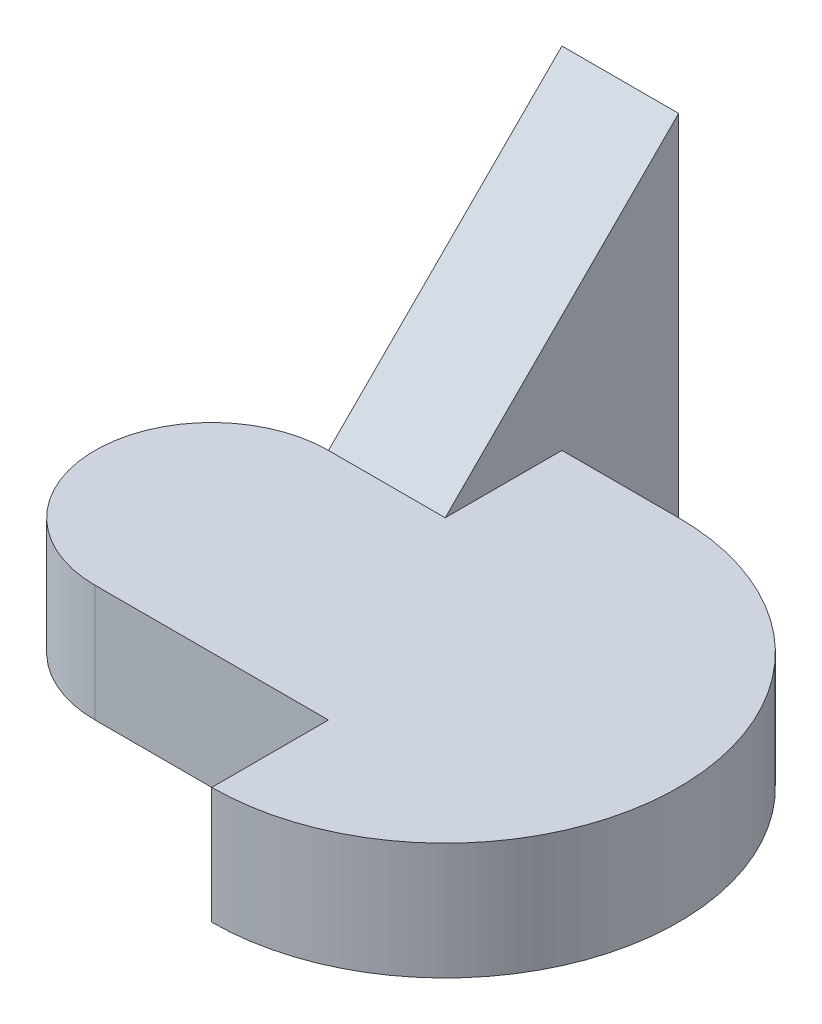
from build123d import *

# Parameters (mm, degrees)
EXTRUDE_1_DEPTH     = 5
EXTRUDE_2_DEPTH     = 15
CUT_EXTRUDE_1_DEPTH = 15


with BuildPart() as part:
    # 草圖1 → 填料-伸長1 (new body)
    with BuildSketch(Plane(origin=(0, 0, 0), x_dir=(1, 0, 0), z_dir=(0, 1, 0))):
        with BuildLine():
            ThreePointArc((-10, 5), (-15, 0), (-10, -5))
            Line((-10, -5), (0, -5))
            Line((0, -5), (0, -10))
            ThreePointArc((0, -10), (10, 0), (0, 10))
            Line((0, 10), (-5, 10))
            Line((-5, 10), (-5, 5))
            Line((-5, 5), (-10, 5))
        make_face()
    extrude(amount=EXTRUDE_1_DEPTH)

    # 草圖1<3> → 填料-伸長2 (add)
    with BuildSketch(Plane(origin=(0, 0, 0), x_dir=(1, 0, 0), z_dir=(0, 1, 0))):
        Polygon((-10, 15), (-10, 5), (-5, 5), (-5, 10), (-5, 15), align=None)
    extrude(amount=EXTRUDE_2_DEPTH)

    # 草圖2 → 除料-伸長1 (cut)
    with BuildSketch(Plane.ZY.offset(10)):
        Polygon((-15, 15), (-5, 5), (-5, 15), align=None)
    extrude(amount=-CUT_EXTRUDE_1_DEPTH, mode=Mode.SUBTRACT)


solid = part.part
